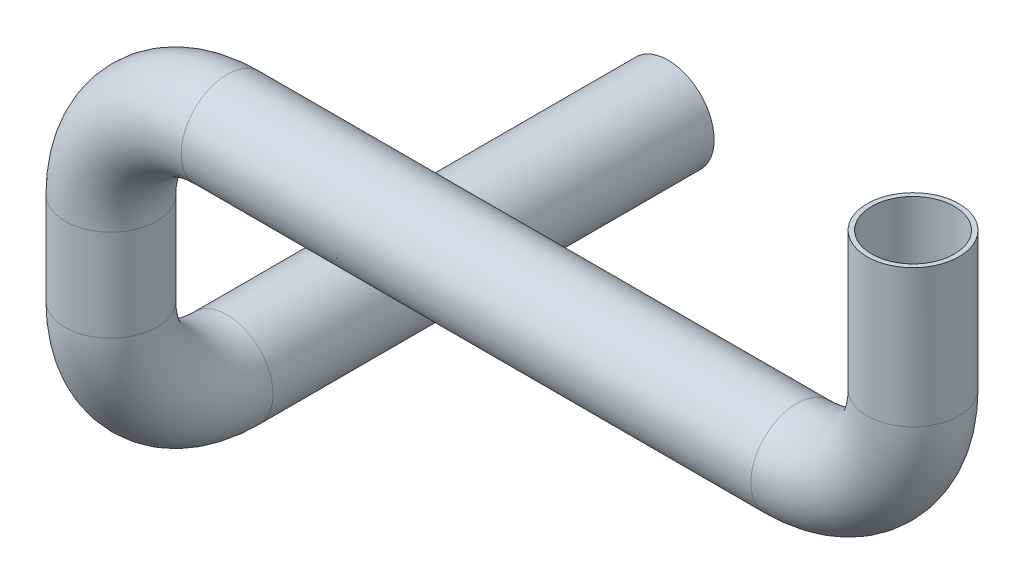
from build123d import *

# Parameters (mm, degrees)
SKETCH2_R = 5
SKETCH6_R = 5
SHELL1_T  = -0.5


with BuildPart() as part:
    # Sweep2: sweep along a path in Sketch1
    with BuildLine(Plane.XY) as sweep2_path:
        Line((43.65, 27.65), (43.65, 12.65))
        ThreePointArc((43.65, 12.65), (39.944900782, 3.705099218), (31, 0))
        Line((31, 0), (-31, 0))
        ThreePointArc((-31, 0), (-39.944900782, -3.705099218), (-43.65, -12.65))
        Line((-43.65, -12.65), (-43.65, -22.65))
    # Sketch2 → Sweep2 (sweep)
    with BuildSketch(Plane(origin=(0, 27.65, 0), x_dir=(1, 0, 0), z_dir=(0, 1, 0))):
        with Locations((43.65, 0)):
            Circle(SKETCH2_R)
    sweep(path=sweep2_path.line)

    # Sweep3: sweep along a path in Sketch5
    with BuildLine(Plane(origin=(-43.65, 0, 0), x_dir=(0, 0, -1), z_dir=(1, 0, 0))) as sweep3_path:
        ThreePointArc((0, -22.65), (3.705099218, -31.594900782), (12.65, -35.3))
        Line((12.65, -35.3), (60.65, -35.3))
    # Sketch6 → Sweep3 (sweep)
    with BuildSketch(Plane.XZ.offset(22.65)):
        with Locations((-43.65, 0)):
            Circle(SKETCH6_R)
    sweep(path=sweep3_path.line)

    # Shell1
    shell1_openings = [part.faces().sort_by_distance(p)[0] for p in [
        (-43.65, -35.3, -60.65),
        (43.65, 27.65, 0),
    ]]
    offset(amount=SHELL1_T, openings=shell1_openings, kind=Kind.INTERSECTION)


solid = part.part
